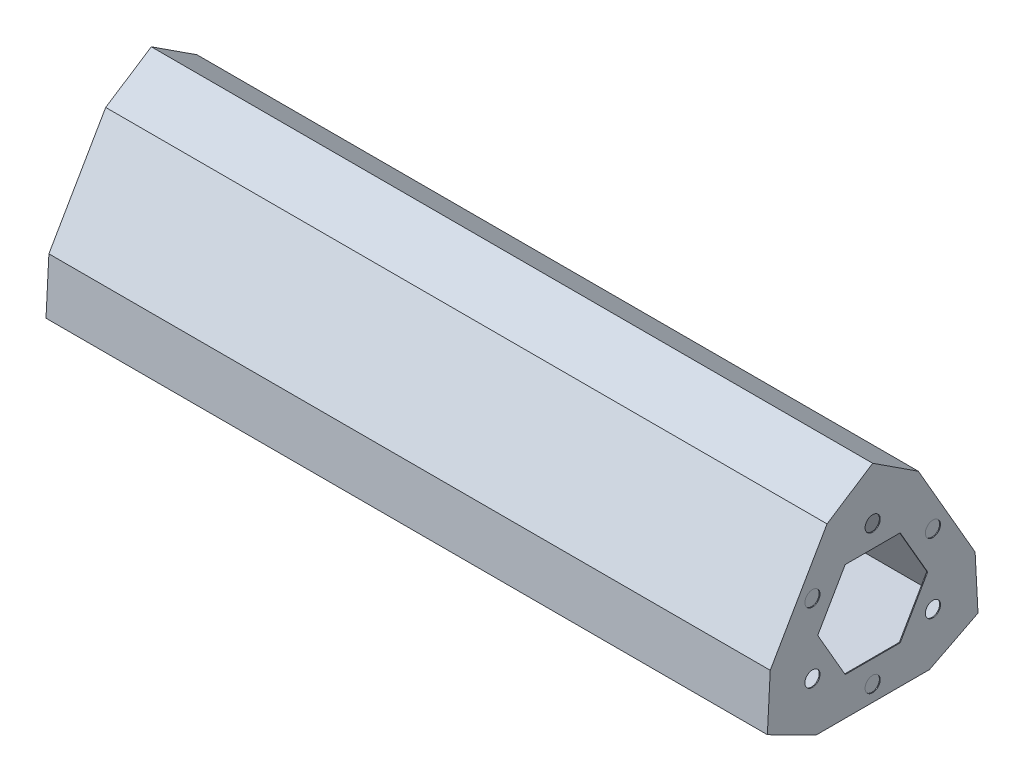
from build123d import *

# Parameters (mm, degrees)
BOSS_EXTRUDE1_DEPTH = 152.4
SKETCH2_R           = 1.6
CUT_EXTRUDE1_DEPTH  = 0.1778
CUT_EXTRUDE4_DEPTH  = 152.0444
SKETCH6_R           = 1.6
CUT_EXTRUDE5_DEPTH  = 0.1778


with BuildPart() as part:
    # Sketch1 → Boss-Extrude1 (new body)
    with BuildSketch(Plane(origin=(0, 0, 0), x_dir=(0, 0, -1), z_dir=(1, 0, 0))):
        Polygon((43.890597967, 11.483842091), (31.890597967, 32.268451781), (22.25, 38.538130468), (44.5, 0), align=None)
        Polygon((22.25, 38.538130468), (44.5, 0), (0, 0), align=None)
        Polygon((0.609402033, 11.483842091), (12.609402033, 32.268451781), (22.25, 38.538130468), (0, 0), align=None)
        Polygon((10.25, -5.214163404), (34.25, -5.214163404), (44.5, 0), (0, 0), align=None)
    extrude(amount=BOSS_EXTRUDE1_DEPTH)

    # Sketch2 → Cut-Extrude1 (cut)
    with BuildSketch(Plane(origin=(152.4, 0, 0), x_dir=(0, 0, -1), z_dir=(1, 0, 0))):
        with Locations((22.25, 27.538130468)):
            Circle(SKETCH2_R)
        with Locations((34.973720558, 20.192086979)):
            Circle(SKETCH2_R)
        with Locations((34.973720558, 5.5)):
            Circle(SKETCH2_R)
        with Locations((22.25, -1.846043489)):
            Circle(SKETCH2_R)
        with Locations((9.526279442, 5.5)):
            Circle(SKETCH2_R)
        with Locations((9.526279442, 20.192086979)):
            Circle(SKETCH2_R)
        Polygon((16.441736842, 22.906250383), (10.633473684, 12.846043489), (16.441736842, 2.785836596), (28.058263158, 2.785836596), (33.866526316, 12.846043489), (28.058263158, 22.906250383), align=None)
    extrude(amount=-CUT_EXTRUDE1_DEPTH, mode=Mode.SUBTRACT)

    # Sketch4 → Cut-Extrude4 (cut)
    with BuildSketch(Plane(origin=(152.2222, 0, 0), x_dir=(0, 0, -1), z_dir=(1, 0, 0))):
        Polygon((22.25, 36.038130468), (2.165063509, 1.25), (42.334936491, 1.25), align=None)
    extrude(amount=-CUT_EXTRUDE4_DEPTH, mode=Mode.SUBTRACT)

    # Sketch6 → Cut-Extrude5 (cut)
    with BuildSketch(Plane.ZY):
        with Locations((-29.964101615, 17.299782134)):
            Circle(SKETCH6_R)
        with Locations((-14.535898385, 17.299782134)):
            Circle(SKETCH6_R)
        with Locations((-22.25, 3.938566201)):
            Circle(SKETCH6_R)
        Polygon((-22.25, 22.660998066), (-30.75, 7.938566201), (-13.75, 7.938566201), align=None)
    extrude(amount=-CUT_EXTRUDE5_DEPTH, mode=Mode.SUBTRACT)


solid = part.part
